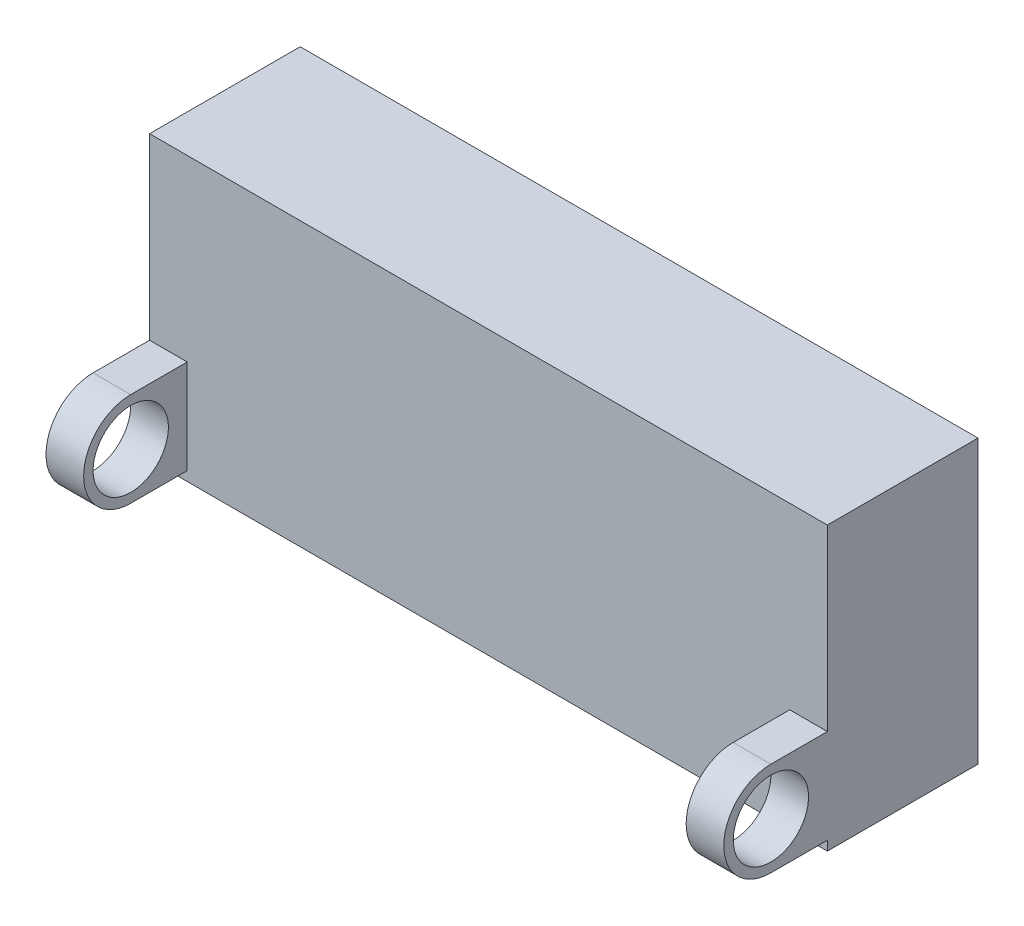
from build123d import *

# Parameters (mm, degrees)
ESQUISSE1_W                = 36
ESQUISSE1_H                = 15
BOSS_EXTRU_3_DEPTH         = 8
ESQUISSE2_R                = 2
BOSS_EXTRU_4_DEPTH         = 2
R_P_TITION_LIN_AIRE1_COUNT = 2
R_P_TITION_LIN_AIRE1_PITCH = 34


with BuildPart() as part:
    # Esquisse1 → Boss.-Extru.3 (new body)
    with BuildSketch(Plane.XY):
        with Locations((18, 7.5)):
            Rectangle(ESQUISSE1_W, ESQUISSE1_H)
    extrude(amount=BOSS_EXTRU_3_DEPTH)

    # Esquisse2 → Boss.-Extru.4 (add)
    with BuildSketch(Plane.ZY):
        with BuildLine():
            Line((11, 5.5), (8, 5.5))
            Line((8, 5.5), (8, 0.5))
            Line((8, 0.5), (11, 0.5))
            ThreePointArc((11, 0.5), (13.5, 3), (11, 5.5))
        make_face()
        with Locations((11, 3)):
            Circle(ESQUISSE2_R, mode=Mode.SUBTRACT)
    boss_extru_4 = extrude(amount=-BOSS_EXTRU_4_DEPTH)

    # Répétition linéaire1: Boss.-Extru.4 ×2
    with Locations(*[(i * R_P_TITION_LIN_AIRE1_PITCH, 0, 0) for i in range(1, R_P_TITION_LIN_AIRE1_COUNT)]):
        add(boss_extru_4)


solid = part.part
